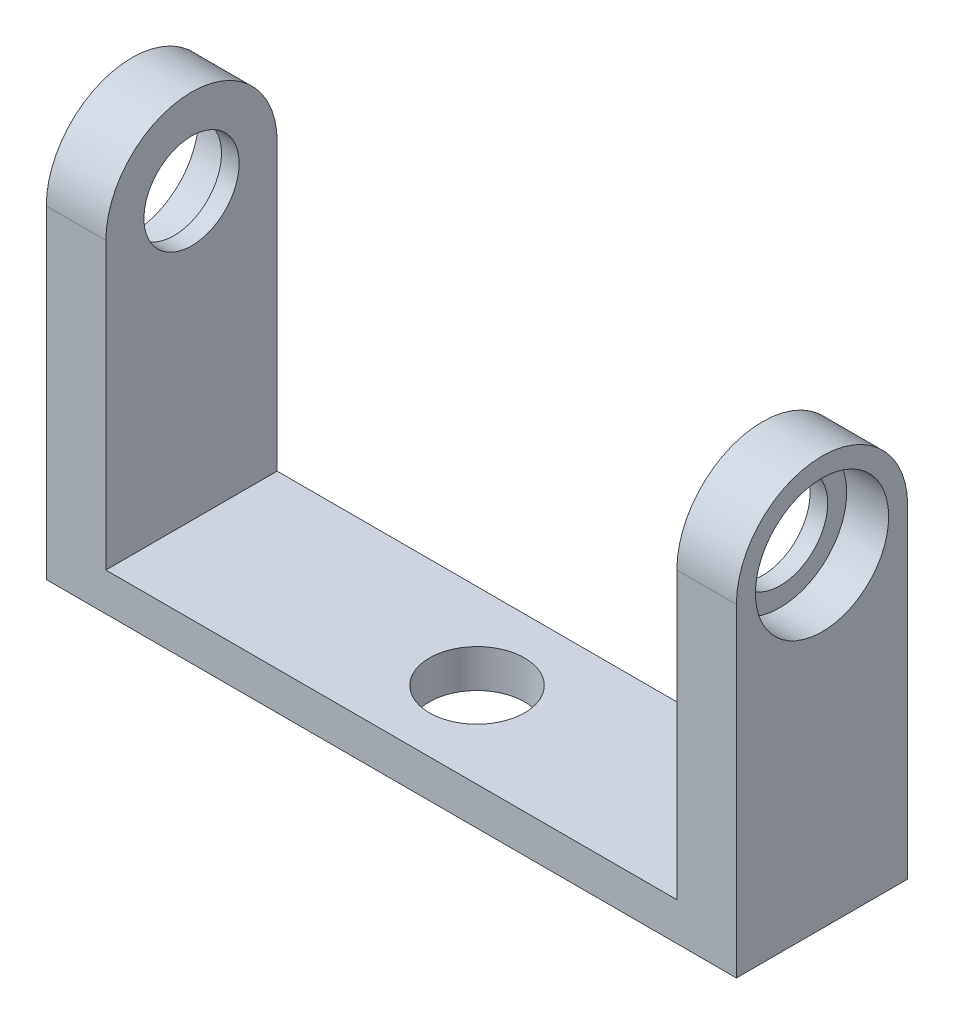
from build123d import *

# Parameters (mm, degrees)
SKETCH1_R           = 9
SKETCH1_R_2         = 5
BOSS_EXTRUDE1_DEPTH = 6.26
BOSS_EXTRUDE2_DEPTH = 6.26
SKETCH2_R           = 7
CUT_EXTRUDE1_DEPTH  = 4.41
SKETCH4_W           = 36.26
SKETCH4_H           = 18
BOSS_EXTRUDE3_DEPTH = 4
SKETCH5_R           = 5
CUT_EXTRUDE2_DEPTH  = 5


with BuildPart() as part:
    # Sketch1 → Boss-Extrude1 (new body)
    with BuildSketch(Plane(origin=(0, 0, 0), x_dir=(0, 0, -1), z_dir=(1, 0, 0))):
        Circle(SKETCH1_R)
        Circle(SKETCH1_R_2, mode=Mode.SUBTRACT)
    extrude(amount=BOSS_EXTRUDE1_DEPTH)

    # Sketch3 → Boss-Extrude2 (add)
    with BuildSketch(Plane.ZY):
        with BuildLine():
            Line((-9, 0), (-9, -30))
            Line((-9, -30), (9, -30))
            Line((9, -30), (9, 0))
            Line((9, 0), (5, 0))
            ThreePointArc((5, 0), (0, -5), (-5, 0))
            Line((-5, 0), (-9, 0))
        make_face()
    extrude(amount=-BOSS_EXTRUDE2_DEPTH)

    # Sketch2 → Cut-Extrude1 (cut)
    with BuildSketch(Plane(origin=(6.26, 0, 0), x_dir=(0, 0, -1), z_dir=(1, 0, 0))):
        Circle(SKETCH2_R)
    extrude(amount=-CUT_EXTRUDE1_DEPTH, mode=Mode.SUBTRACT)

    # Sketch4 → Boss-Extrude3 (add)
    with BuildSketch(Plane.XZ.offset(30)):
        with Locations((-11.87, 0)):
            Rectangle(SKETCH4_W, SKETCH4_H)
    extrude(amount=BOSS_EXTRUDE3_DEPTH)

    # Mirror2: part across plane


with BuildPart() as part_1:
    add(part.part)
    add(part.part.mirror(Plane(origin=(-30, -34, 9), x_dir=(0, 0, 1), z_dir=(1, 0, 0))))

    # Sketch5 → Cut-Extrude2 (cut, through all)
    with BuildSketch(Plane(origin=(0, -30, 0), x_dir=(1, 0, 0), z_dir=(0, 1, 0))):
        with Locations((-30, 0)):
            Circle(SKETCH5_R)
    extrude(amount=-CUT_EXTRUDE2_DEPTH, mode=Mode.SUBTRACT)


solid = part_1.part
